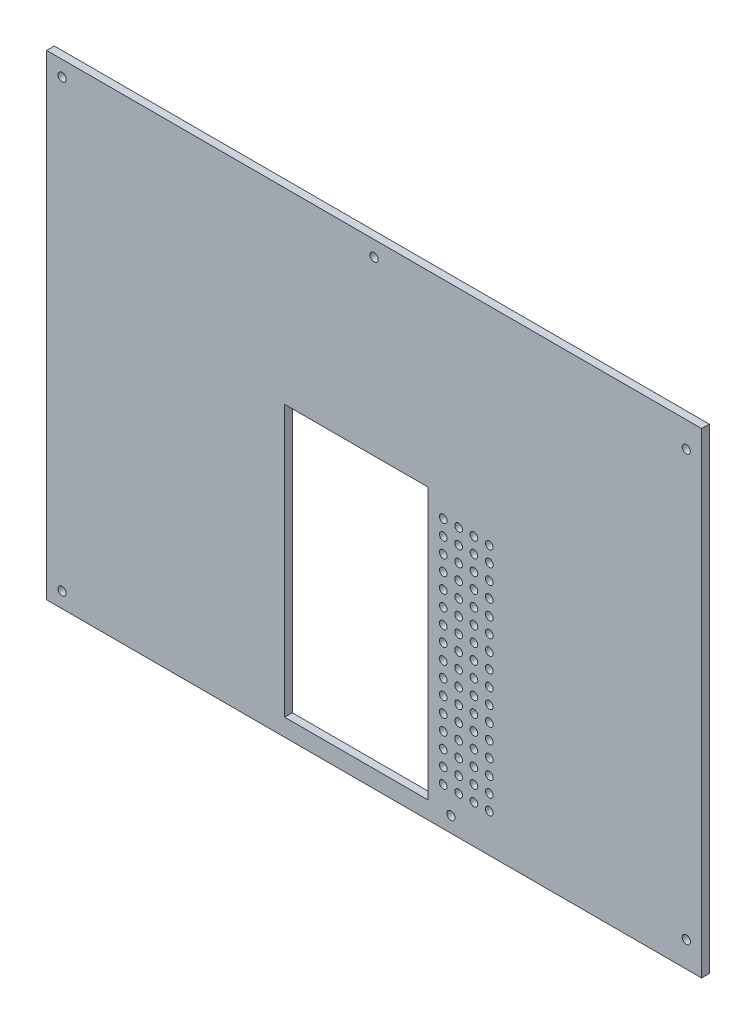
from build123d import *

# Parameters (mm, degrees)
SKETCH2_W           = 256
SKETCH2_H           = 186
BOSS_EXTRUDE1_DEPTH = 3
SKETCH3_R           = 1.6
CUT_EXTRUDE1_DEPTH  = 4
SKETCH4_W           = 56
SKETCH4_H           = 105.9
CUT_EXTRUDE2_DEPTH  = 4
SKETCH5_R           = 1.5
CUT_EXTRUDE3_DEPTH  = 4


with BuildPart() as part:
    # Sketch2 → Boss-Extrude1 (new body)
    with BuildSketch(Plane.XY):
        with Locations((128, 93)):
            Rectangle(SKETCH2_W, SKETCH2_H)
    extrude(amount=BOSS_EXTRUDE1_DEPTH)

    # Sketch3 → Cut-Extrude1 (cut, through all)
    with BuildSketch(Plane.XY.offset(3)):
        with Locations((6, 180)):
            Circle(SKETCH3_R)
        with Locations((128, 180)):
            Circle(SKETCH3_R)
        with Locations((6, 6)):
            Circle(SKETCH3_R)
        with Locations((250, 176)):
            Circle(SKETCH3_R)
        with Locations((250, 10)):
            Circle(SKETCH3_R)
        with Locations((158, 6)):
            Circle(SKETCH3_R)
    extrude(amount=-CUT_EXTRUDE1_DEPTH, mode=Mode.SUBTRACT)

    # Sketch4 → Cut-Extrude2 (cut, through all)
    with BuildSketch(Plane.XY.offset(3)):
        with Locations((121, 59.75)):
            Rectangle(SKETCH4_W, SKETCH4_H)
    extrude(amount=-CUT_EXTRUDE2_DEPTH, mode=Mode.SUBTRACT)

    # Sketch5 → Cut-Extrude3 (cut, through all)
    with BuildSketch(Plane.XY.offset(3)):
        with Locations((173, 105)):
            Circle(SKETCH5_R)
        with Locations((167, 105)):
            Circle(SKETCH5_R)
        with Locations((161, 105)):
            Circle(SKETCH5_R)
        with Locations((155, 105)):
            Circle(SKETCH5_R)
        with Locations((167, 99)):
            Circle(SKETCH5_R)
        with Locations((161, 99)):
            Circle(SKETCH5_R)
        with Locations((155, 99)):
            Circle(SKETCH5_R)
        with Locations((167, 93)):
            Circle(SKETCH5_R)
        with Locations((161, 93)):
            Circle(SKETCH5_R)
        with Locations((155, 93)):
            Circle(SKETCH5_R)
        with Locations((167, 87)):
            Circle(SKETCH5_R)
        with Locations((161, 87)):
            Circle(SKETCH5_R)
        with Locations((155, 87)):
            Circle(SKETCH5_R)
        with Locations((167, 81)):
            Circle(SKETCH5_R)
        with Locations((161, 81)):
            Circle(SKETCH5_R)
        with Locations((155, 81)):
            Circle(SKETCH5_R)
        with Locations((167, 75)):
            Circle(SKETCH5_R)
        with Locations((161, 75)):
            Circle(SKETCH5_R)
        with Locations((155, 75)):
            Circle(SKETCH5_R)
        with Locations((167, 69)):
            Circle(SKETCH5_R)
        with Locations((161, 69)):
            Circle(SKETCH5_R)
        with Locations((155, 69)):
            Circle(SKETCH5_R)
        with Locations((167, 63)):
            Circle(SKETCH5_R)
        with Locations((161, 63)):
            Circle(SKETCH5_R)
        with Locations((155, 63)):
            Circle(SKETCH5_R)
        with Locations((167, 57)):
            Circle(SKETCH5_R)
        with Locations((161, 57)):
            Circle(SKETCH5_R)
        with Locations((155, 57)):
            Circle(SKETCH5_R)
        with Locations((167, 51)):
            Circle(SKETCH5_R)
        with Locations((161, 51)):
            Circle(SKETCH5_R)
        with Locations((155, 51)):
            Circle(SKETCH5_R)
        with Locations((167, 45)):
            Circle(SKETCH5_R)
        with Locations((161, 45)):
            Circle(SKETCH5_R)
        with Locations((155, 45)):
            Circle(SKETCH5_R)
        with Locations((167, 39)):
            Circle(SKETCH5_R)
        with Locations((161, 39)):
            Circle(SKETCH5_R)
        with Locations((155, 39)):
            Circle(SKETCH5_R)
        with Locations((167, 33)):
            Circle(SKETCH5_R)
        with Locations((161, 33)):
            Circle(SKETCH5_R)
        with Locations((155, 33)):
            Circle(SKETCH5_R)
        with Locations((167, 27)):
            Circle(SKETCH5_R)
        with Locations((161, 27)):
            Circle(SKETCH5_R)
        with Locations((155, 27)):
            Circle(SKETCH5_R)
        with Locations((167, 21)):
            Circle(SKETCH5_R)
        with Locations((161, 21)):
            Circle(SKETCH5_R)
        with Locations((155, 21)):
            Circle(SKETCH5_R)
        with Locations((167, 15)):
            Circle(SKETCH5_R)
        with Locations((161, 15)):
            Circle(SKETCH5_R)
        with Locations((155, 15)):
            Circle(SKETCH5_R)
        with Locations((173, 99)):
            Circle(SKETCH5_R)
        with Locations((173, 93)):
            Circle(SKETCH5_R)
        with Locations((173, 87)):
            Circle(SKETCH5_R)
        with Locations((173, 81)):
            Circle(SKETCH5_R)
        with Locations((173, 75)):
            Circle(SKETCH5_R)
        with Locations((173, 69)):
            Circle(SKETCH5_R)
        with Locations((173, 63)):
            Circle(SKETCH5_R)
        with Locations((173, 57)):
            Circle(SKETCH5_R)
        with Locations((173, 51)):
            Circle(SKETCH5_R)
        with Locations((173, 45)):
            Circle(SKETCH5_R)
        with Locations((173, 39)):
            Circle(SKETCH5_R)
        with Locations((173, 33)):
            Circle(SKETCH5_R)
        with Locations((173, 27)):
            Circle(SKETCH5_R)
        with Locations((173, 21)):
            Circle(SKETCH5_R)
        with Locations((173, 15)):
            Circle(SKETCH5_R)
    extrude(amount=-CUT_EXTRUDE3_DEPTH, mode=Mode.SUBTRACT)


solid = part.part
